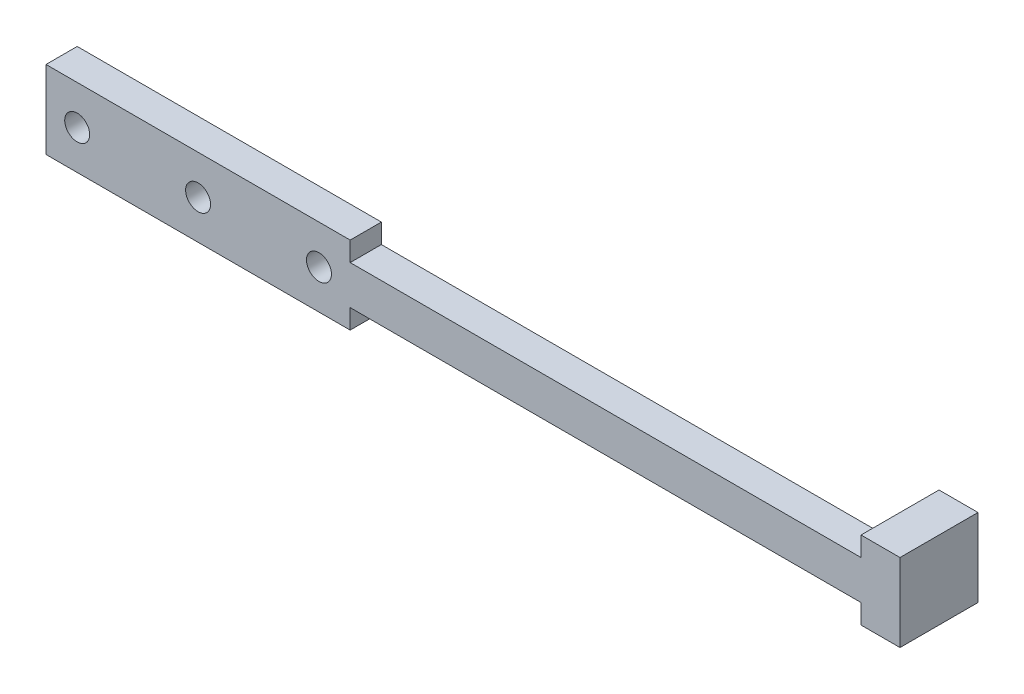
from build123d import *

# Parameters (mm, degrees)
ESBO_O1_R                = 1.6
ESBO_O1_W                = 65.5
ESBO_O1_H                = 5
RESSALTO_EXTRUS_O1_DEPTH = 4
ESBO_O2_W                = 5
ESBO_O2_H                = 10
RESSALTO_EXTRUS_O2_DEPTH = 10


with BuildPart() as part:
    # Esboço1 → Ressalto-extrusão1 (new body)
    with BuildSketch(Plane.XY):
        Polygon((-32.75, -2.5), (-32.75, -5), (-71.75, -5), (-71.75, 5), (-32.75, 5), (-32.75, 2.5), align=None)
        with Locations((-52.25, 0)):
            Circle(ESBO_O1_R, mode=Mode.SUBTRACT)
        with Locations((-67.75, 0)):
            Circle(ESBO_O1_R, mode=Mode.SUBTRACT)
        with Locations((-36.75, 0)):
            Circle(ESBO_O1_R, mode=Mode.SUBTRACT)
        Rectangle(ESBO_O1_W, ESBO_O1_H)
    extrude(amount=RESSALTO_EXTRUS_O1_DEPTH)

    # Esboço2 → Ressalto-extrusão2 (add)
    with BuildSketch(Plane.XY.offset(4)):
        with Locations((35.25, 0)):
            Rectangle(ESBO_O2_W, ESBO_O2_H)
    extrude(amount=-RESSALTO_EXTRUS_O2_DEPTH)


solid = part.part
